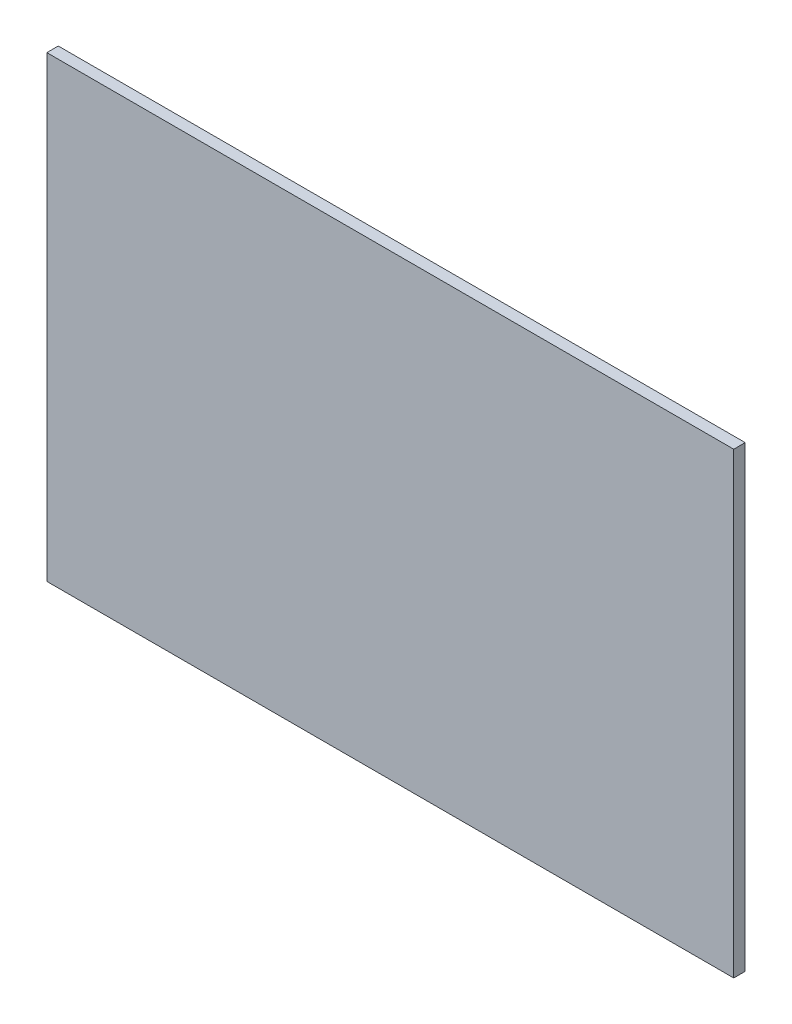
from build123d import *

# Parameters (mm, degrees)
ESQUISSE2_W        = 300
ESQUISSE2_H        = 200
BOSS_EXTRU_1_DEPTH = 5


with BuildPart() as part:
    # Esquisse2 → Boss.-Extru.1 (new body)
    with BuildSketch(Plane.XY):
        with Locations((82.158380627, 89.780663506)):
            Rectangle(ESQUISSE2_W, ESQUISSE2_H)
    extrude(amount=BOSS_EXTRU_1_DEPTH)


solid = part.part
